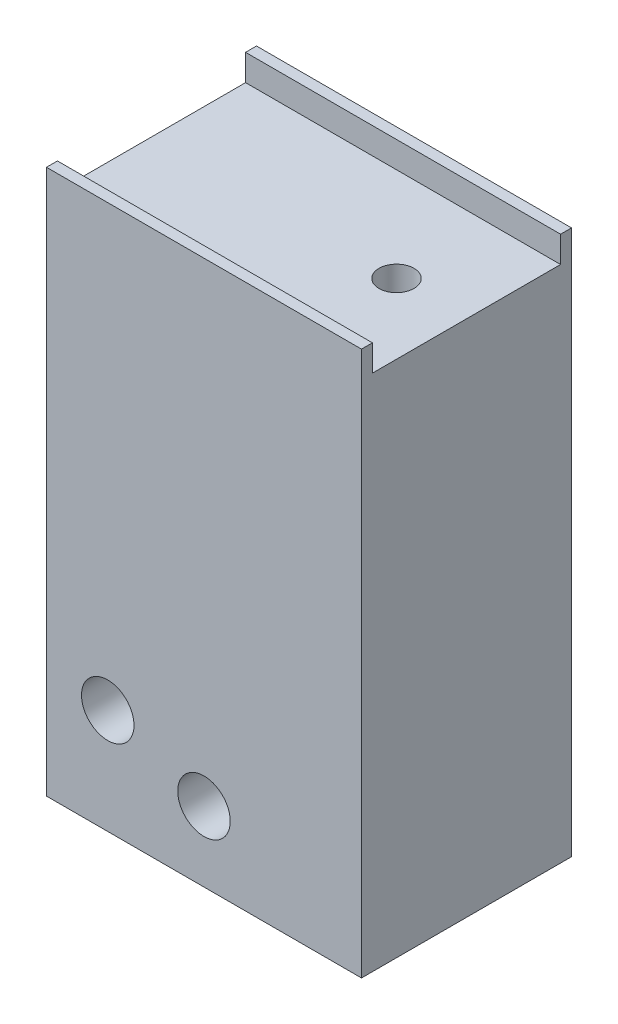
from build123d import *

# Parameters (mm, degrees)
BOSS_EXTRUDE1_DEPTH = 8
CUT_EXTRUDE1_REACH  = 12
SKETCH3_R           = 1
BOSS_EXTRUDE2_DEPTH = 10
SKETCH7_W           = 18
SKETCH7_H           = 12
SKETCH7_R           = 1
BOSS_EXTRUDE3_DEPTH = 21.12
SKETCH11_R          = 1.5
CUT_EXTRUDE4_DEPTH  = 13


with BuildPart() as part:
    # Sketch2 → Boss-Extrude1 (new body)
    with BuildSketch(Plane(origin=(0, 0, 0), x_dir=(0, 0, -1), z_dir=(1, 0, 0))):
        Polygon((0, 0), (0, 10), (0.625, 10), (0.625, 8.5), (11.375, 8.5), (11.375, 10), (12, 10), (12, 0), align=None)
    extrude(amount=BOSS_EXTRUDE1_DEPTH)

    # Sketch3 → Cut-Extrude1 (cut, up to next)
    with BuildSketch(Plane.XZ, mode=Mode.PRIVATE) as cut_extrude1_sk1:
        with Locations((4, -6)):
            Circle(SKETCH3_R)
    cut_extrude1_tool1 = extrude(cut_extrude1_sk1.sketch, amount=-CUT_EXTRUDE1_REACH, mode=Mode.PRIVATE) & part.part
    add(cut_extrude1_tool1.solids().sort_by_distance((4, 0, -6))[0], mode=Mode.SUBTRACT)

    # Sketch6 → Boss-Extrude2 (add)
    with BuildSketch(Plane.ZY):
        Polygon((-12, 0), (0, 0), (0, 10), (-0.625, 10), (-0.625, 8.5), (-11.375, 8.5), (-11.375, 10), (-12, 10), align=None)
    extrude(amount=BOSS_EXTRUDE2_DEPTH)

    # Sketch7 → Boss-Extrude3 (add)
    with BuildSketch(Plane.XZ):
        with Locations((-1, -6)):
            Rectangle(SKETCH7_W, SKETCH7_H)
        with Locations((4, -6)):
            Circle(SKETCH7_R, mode=Mode.SUBTRACT)
    extrude(amount=BOSS_EXTRUDE3_DEPTH)

    # Sketch11 → Cut-Extrude4 (cut, through all)
    with BuildSketch(Plane.XY):
        with Locations((-6.5, -15.12)):
            Circle(SKETCH11_R)
        with Locations((-1, -17.12)):
            Circle(SKETCH11_R)
    extrude(amount=-CUT_EXTRUDE4_DEPTH, mode=Mode.SUBTRACT)


solid = part.part
